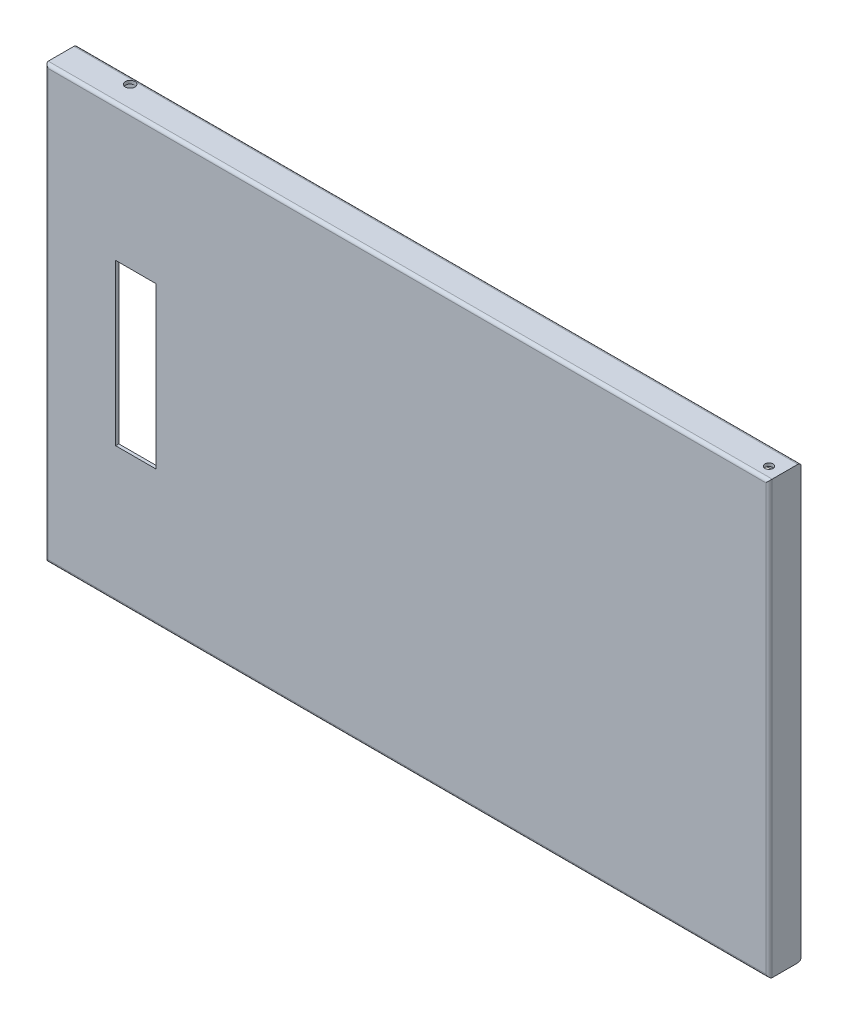
from build123d import *

# Parameters (mm, degrees)
SKETCH1_W           = 451
SKETCH1_H           = 269
BOSS_EXTRUDE1_DEPTH = 20
SHELL1_T            = -11
SKETCH2_W           = 429
SKETCH2_H           = 247
CUT_EXTRUDE1_DEPTH  = 9
SKETCH4_W           = 16
SKETCH4_H           = 247
CUT_EXTRUDE3_DEPTH  = 9
SKETCH8_W           = 438
SKETCH8_H           = 16
CUT_EXTRUDE4_DEPTH  = 9
SKETCH9_W           = 16
SKETCH9_H           = 256
CUT_EXTRUDE5_DEPTH  = 9
SKETCH10_W          = 447
SKETCH10_H          = 16
CUT_EXTRUDE6_DEPTH  = 9
SKETCH11_W          = 25
SKETCH11_H          = 100
CUT_EXTRUDE7_DEPTH  = 2
FILLET1_R           = 2
FILLET2_R           = 2
SKETCH12_R          = 3
CUT_EXTRUDE8_DEPTH  = 2
SKETCH13_R          = 4.399472723
CUT_EXTRUDE9_DEPTH  = 2
SKETCH14_R          = 2.5
CUT_EXTRUDE10_DEPTH = 270


with BuildPart() as part:
    # Sketch1 → Boss-Extrude1 (new body)
    with BuildSketch(Plane.XY):
        Rectangle(SKETCH1_W, SKETCH1_H)
    extrude(amount=BOSS_EXTRUDE1_DEPTH)

    # Shell1
    shell1_openings = [part.faces().sort_by_distance(p)[0] for p in [
        (0, 0, 0),
    ]]
    offset(amount=SHELL1_T, openings=shell1_openings, kind=Kind.INTERSECTION)

    # Sketch2 → Cut-Extrude1 (cut)
    with BuildSketch(Plane(origin=(0, 0, 9), x_dir=(-1, 0, 0), z_dir=(0, 0, -1))):
        Rectangle(SKETCH2_W, SKETCH2_H)
    extrude(amount=-CUT_EXTRUDE1_DEPTH, mode=Mode.SUBTRACT)

    # Sketch4 → Cut-Extrude3 (cut)
    with BuildSketch(Plane.ZY.offset(-214.5)):
        with Locations((10, 0)):
            Rectangle(SKETCH4_W, SKETCH4_H)
    extrude(amount=-CUT_EXTRUDE3_DEPTH, mode=Mode.SUBTRACT)

    # Sketch8 → Cut-Extrude4 (cut)
    with BuildSketch(Plane.XZ.offset(-123.5)):
        with Locations((4.5, 10)):
            Rectangle(SKETCH8_W, SKETCH8_H)
    extrude(amount=-CUT_EXTRUDE4_DEPTH, mode=Mode.SUBTRACT)

    # Sketch9 → Cut-Extrude5 (cut)
    with BuildSketch(Plane(origin=(-214.5, 0, 0), x_dir=(0, 0, -1), z_dir=(1, 0, 0))):
        with Locations((-10, 4.5)):
            Rectangle(SKETCH9_W, SKETCH9_H)
    extrude(amount=-CUT_EXTRUDE5_DEPTH, mode=Mode.SUBTRACT)

    # Sketch10 → Cut-Extrude6 (cut)
    with BuildSketch(Plane(origin=(0, -123.5, 0), x_dir=(1, 0, 0), z_dir=(0, 1, 0))):
        with Locations((0, -10)):
            Rectangle(SKETCH10_W, SKETCH10_H)
    extrude(amount=-CUT_EXTRUDE6_DEPTH, mode=Mode.SUBTRACT)

    # Sketch11 → Cut-Extrude7 (cut)
    with BuildSketch(Plane.XY.offset(20)):
        with Locations((-169, 0)):
            Rectangle(SKETCH11_W, SKETCH11_H)
    extrude(amount=-CUT_EXTRUDE7_DEPTH, mode=Mode.SUBTRACT)

    # Fillet1
    fillet1_edges = [part.edges().sort_by_distance(p)[0] for p in [
        (-225.5, 0, 20),
        (0, -134.5, 20),
        (223.5, 0, 2),
        (225.5, 0, 20),
        (0, -134.5, 0),
        (-225.5, 0, 0),
        (0, 134.5, 0),
        (0, 134.5, 20),
    ]]
    fillet(fillet1_edges, radius=FILLET1_R)

    # Fillet2
    fillet2_edges = [part.edges().sort_by_distance(p)[0] for p in [
        (223.5, 0, 18),
        (0, 132.5, 18),
        (-223.5, 0, 18),
        (0, -132.5, 18),
    ]]
    fillet(fillet2_edges, radius=FILLET2_R)

    # Sketch12 → Cut-Extrude8 (cut)
    with BuildSketch(Plane(origin=(0, 134.5, 0), x_dir=(1, 0, 0), z_dir=(0, 1, 0))):
        with Locations((-187.5, -5)):
            Circle(SKETCH12_R)
    extrude(amount=-CUT_EXTRUDE8_DEPTH, mode=Mode.SUBTRACT)

    # Sketch13 → Cut-Extrude9 (cut)
    with BuildSketch(Plane.XZ.offset(134.5)):
        with Locations((-150.5, 5)):
            Circle(SKETCH13_R)
    extrude(amount=-CUT_EXTRUDE9_DEPTH, mode=Mode.SUBTRACT)

    # Sketch14 → Cut-Extrude10 (cut, through all)
    with BuildSketch(Plane.XZ.offset(134.5)):
        with Locations((217.5, 12)):
            Circle(SKETCH14_R)
    extrude(amount=-CUT_EXTRUDE10_DEPTH, mode=Mode.SUBTRACT)


solid = part.part
